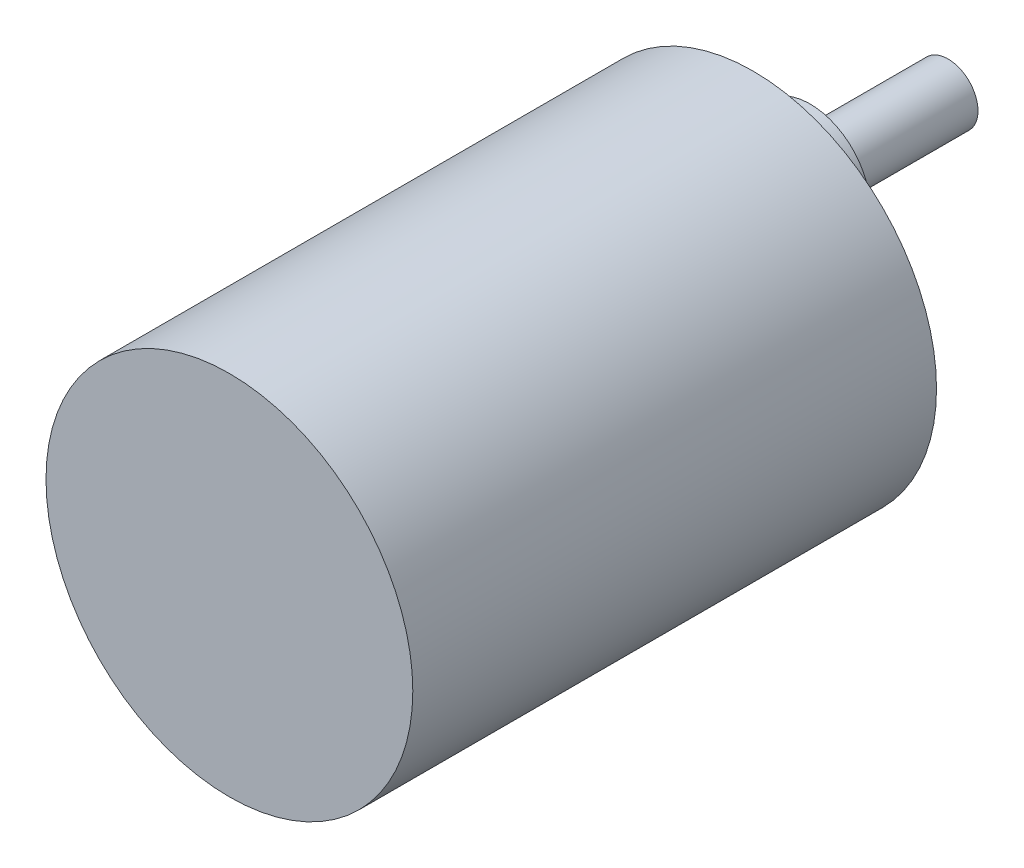
from build123d import *

# Parameters (mm, degrees)
SKETCH_1_R          = 18.35
EXTRUDE_1_DEPTH     = 52.4
SKETCH_1_4_R        = 6
EXTRUDE_2_DEPTH     = 5.7
SKETCH_1_5_R        = 3
EXTRUDE_3_DEPTH     = 19.5
SKETCH_1_6_R        = 1.5
CUT_EXTRUDE_1_DEPTH = 3


with BuildPart() as part:
    # 草图1 → 凸台-拉伸1 (new body)
    with BuildSketch(Plane.XY):
        Circle(SKETCH_1_R)
    extrude(amount=EXTRUDE_1_DEPTH)

    # 草图1<4> → 凸台-拉伸2 (add)
    with BuildSketch(Plane.XY):
        with Locations((0, 6.65)):
            Circle(SKETCH_1_4_R)
    extrude(amount=-EXTRUDE_2_DEPTH)

    # 草图1<5> → 凸台-拉伸3 (add)
    with BuildSketch(Plane.XY):
        with Locations((0, 6.65)):
            Circle(SKETCH_1_5_R)
    extrude(amount=-EXTRUDE_3_DEPTH)

    # 草图1<6> → 切除-拉伸1 (cut)
    with BuildSketch(Plane.XY):
        with Locations((-15.5, 0)):
            Circle(SKETCH_1_6_R)
        with Locations((15.5, 0)):
            Circle(SKETCH_1_6_R)
    extrude(amount=CUT_EXTRUDE_1_DEPTH, mode=Mode.SUBTRACT)


solid = part.part
